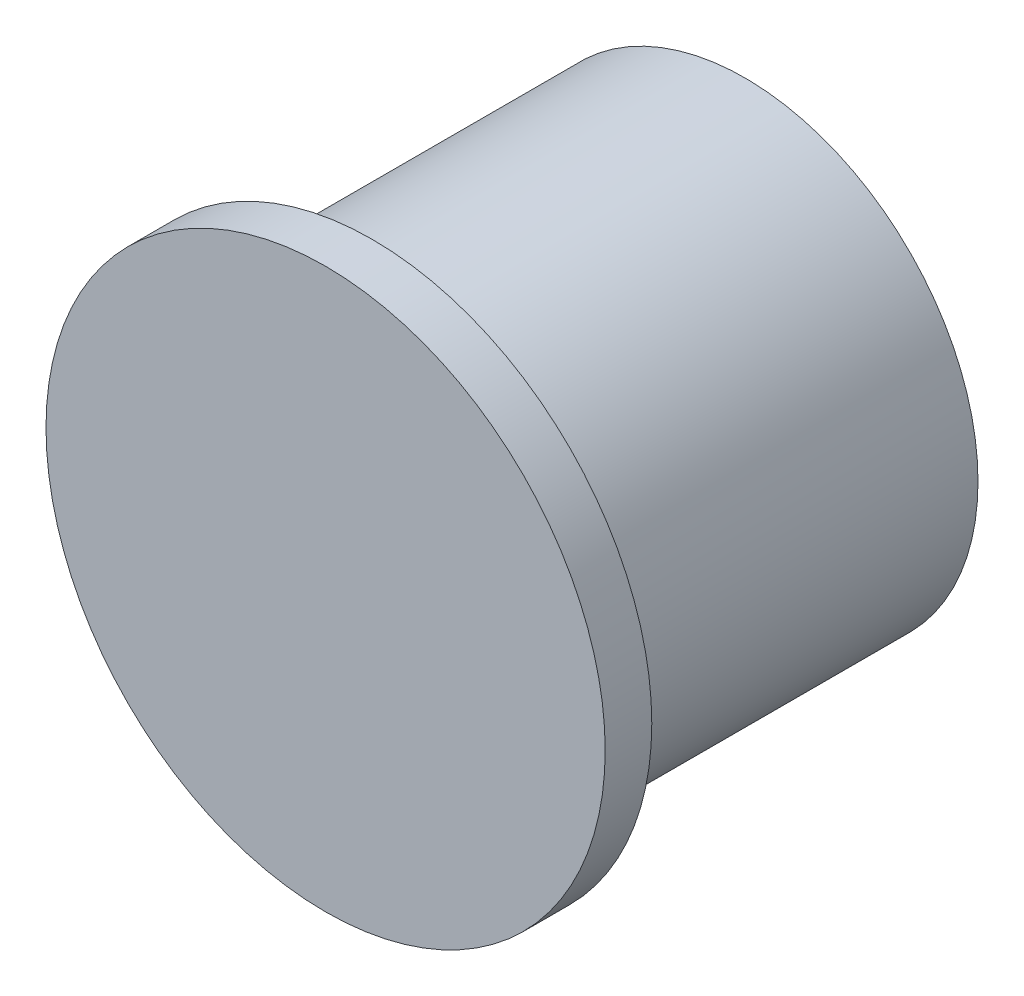
from build123d import *

# Parameters (mm, degrees)
SKETCH1_R           = 5
BOSS_EXTRUDE1_DEPTH = 8
SKETCH2_R           = 6
BOSS_EXTRUDE2_DEPTH = 1


with BuildPart() as part:
    # Sketch1 → Boss-Extrude1 (new body)
    with BuildSketch(Plane.XY):
        Circle(SKETCH1_R)
    extrude(amount=BOSS_EXTRUDE1_DEPTH)

    # Sketch2 → Boss-Extrude2 (add)
    with BuildSketch(Plane.XY.offset(8)):
        Circle(SKETCH2_R)
    extrude(amount=BOSS_EXTRUDE2_DEPTH)


solid = part.part
